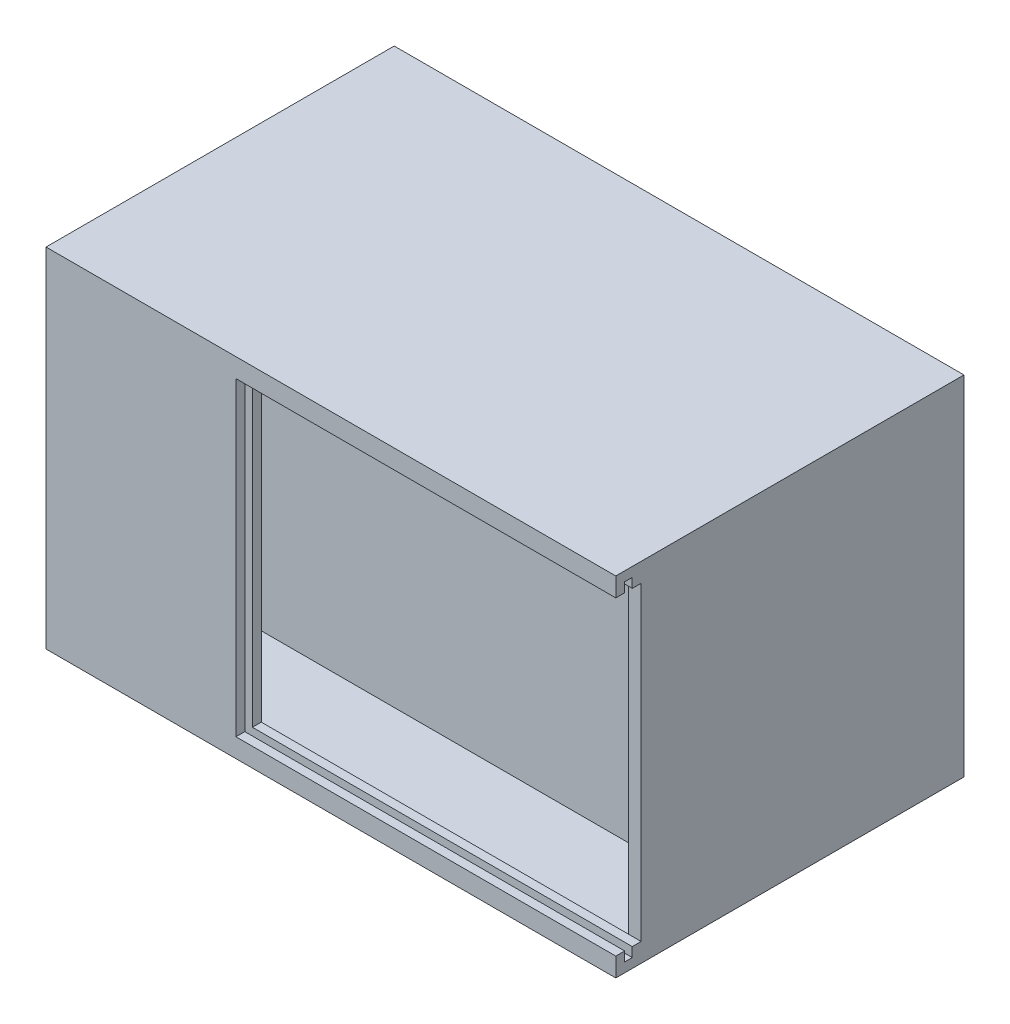
from build123d import *

# Parameters (mm, degrees)
SKETCH1_W           = 90
SKETCH1_H           = 55
BOSS_EXTRUDE1_DEPTH = 55
SHELL1_T            = -2
SKETCH2_W           = 4
SKETCH2_H           = 55
BOSS_EXTRUDE2_DEPTH = 88
SKETCH3_W           = 4
SKETCH3_H           = 49
CUT_EXTRUDE1_DEPTH  = 60
SKETCH4_W           = 1.2
SKETCH4_H           = 52
CUT_EXTRUDE2_DEPTH  = 61.5
CUT_EXTRUDE3_START  = -10
SKETCH5_W           = 13
SKETCH5_H           = 19.5
CUT_EXTRUDE3_DEPTH  = 46
SKETCH7_R           = 5
BOSS_EXTRUDE3_DEPTH = 5
SKETCH8_R           = 1.4
CUT_EXTRUDE4_DEPTH  = 5
BOSS_EXTRUDE4_REACH = 90
SKETCH9_W           = 4
SKETCH9_H           = 51


with BuildPart() as part:
    # Sketch1 → Boss-Extrude1 (new body)
    with BuildSketch(Plane.XY):
        Rectangle(SKETCH1_W, SKETCH1_H)
    extrude(amount=BOSS_EXTRUDE1_DEPTH)

    # Shell1
    shell1_openings = [part.faces().sort_by_distance(p)[0] for p in [
        (0, 0, 55),
    ]]
    offset(amount=SHELL1_T, openings=shell1_openings, kind=Kind.INTERSECTION)

    # Sketch2 → Boss-Extrude2 (add)
    with BuildSketch(Plane(origin=(45, 0, 0), x_dir=(0, 0, -1), z_dir=(1, 0, 0))):
        with Locations((-53, 0)):
            Rectangle(SKETCH2_W, SKETCH2_H)
    extrude(amount=-BOSS_EXTRUDE2_DEPTH)

    # Sketch3 → Cut-Extrude1 (cut)
    with BuildSketch(Plane(origin=(45, 0, 0), x_dir=(0, 0, -1), z_dir=(1, 0, 0))):
        with Locations((-53, 0)):
            Rectangle(SKETCH3_W, SKETCH3_H)
    extrude(amount=-CUT_EXTRUDE1_DEPTH, mode=Mode.SUBTRACT)

    # Sketch4 → Cut-Extrude2 (cut)
    with BuildSketch(Plane(origin=(45, 0, 0), x_dir=(0, 0, -1), z_dir=(1, 0, 0))):
        with Locations((-53, 0)):
            Rectangle(SKETCH4_W, SKETCH4_H)
    extrude(amount=-CUT_EXTRUDE2_DEPTH, mode=Mode.SUBTRACT)

    # Sketch5 → Cut-Extrude3 (cut, through all)
    with BuildSketch(Plane.XY.offset(55).offset(CUT_EXTRUDE3_START)):
        with Locations((-32.5, -0.25)):
            Rectangle(SKETCH5_W, SKETCH5_H)
    extrude(amount=-CUT_EXTRUDE3_DEPTH, mode=Mode.SUBTRACT)

    # Sketch7 → Boss-Extrude3 (add)
    with BuildSketch(Plane.XY.offset(2)):
        with Locations((3, 19.5)):
            Circle(SKETCH7_R)
        with Locations((-13, -9)):
            Circle(SKETCH7_R)
        with Locations((13, 17.5)):
            Circle(SKETCH7_R)
        with Locations((37, -6.5)):
            Circle(SKETCH7_R)
    extrude(amount=BOSS_EXTRUDE3_DEPTH)

    # Sketch8 → Cut-Extrude4 (cut)
    with BuildSketch(Plane.XY.offset(7)):
        with Locations((13, 17.5)):
            Circle(SKETCH8_R)
        with Locations((-13, -9)):
            Circle(SKETCH8_R)
        with Locations((37, -6.5)):
            Circle(SKETCH8_R)
        with Locations((3, 19.5)):
            Circle(SKETCH8_R)
    extrude(amount=-CUT_EXTRUDE4_DEPTH, mode=Mode.SUBTRACT)

    # Sketch9 → Boss-Extrude4 (add, up to next)
    with BuildSketch(Plane(origin=(-43, 0, 0), x_dir=(0, 0, -1), z_dir=(1, 0, 0)), mode=Mode.PRIVATE) as boss_extrude4_sk1:
        with Locations((-35.5, 0)):
            Rectangle(SKETCH9_W, SKETCH9_H)
    boss_extrude4_tool1 = extrude(boss_extrude4_sk1.sketch, amount=BOSS_EXTRUDE4_REACH, mode=Mode.PRIVATE) - part.part
    add(boss_extrude4_tool1.solids().sort_by_distance((-43, 0, 35.5))[0])


solid = part.part
